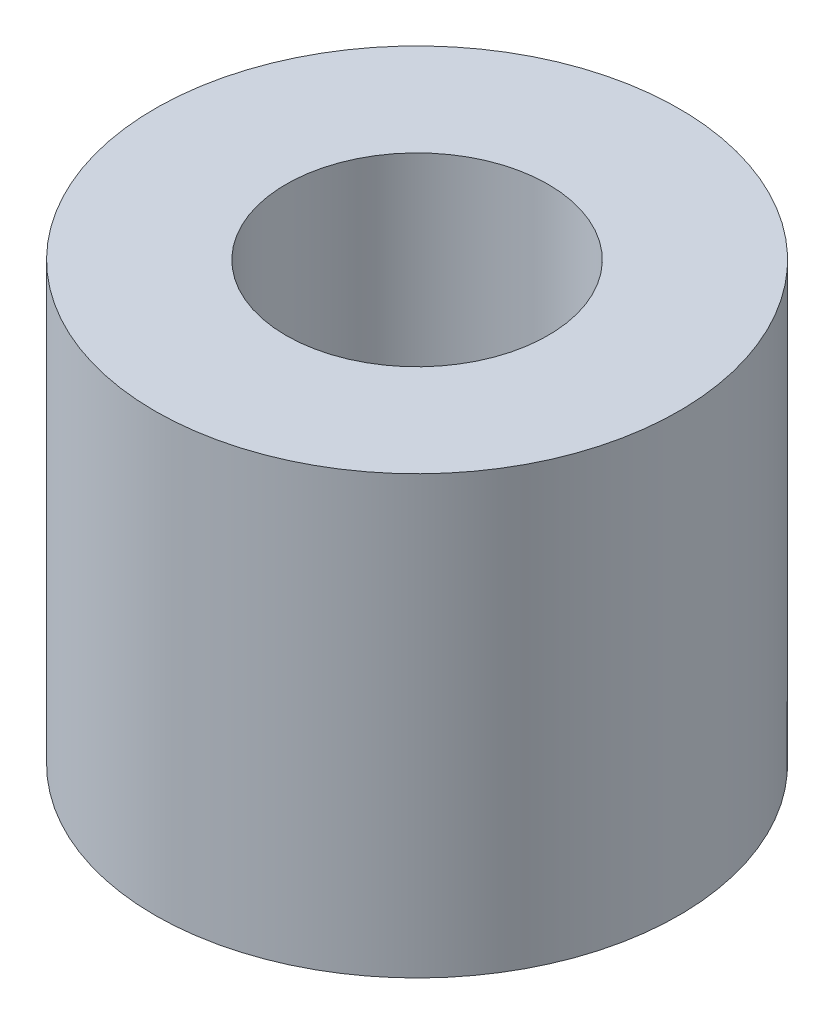
from build123d import *

# Parameters (mm, degrees)
SKETCH1_R           = 3
BOSS_EXTRUDE1_DEPTH = 5
SKETCH2_R           = 1.5
CUT_EXTRUDE1_DEPTH  = 4


with BuildPart() as part:
    # Sketch1 → Boss-Extrude1 (new body)
    with BuildSketch(Plane(origin=(0, 0, 0), x_dir=(1, 0, 0), z_dir=(0, 1, 0))):
        Circle(SKETCH1_R)
    extrude(amount=BOSS_EXTRUDE1_DEPTH)

    # Sketch2 → Cut-Extrude1 (cut)
    with BuildSketch(Plane(origin=(0, 5, 0), x_dir=(1, 0, 0), z_dir=(0, 1, 0))):
        Circle(SKETCH2_R)
    extrude(amount=-CUT_EXTRUDE1_DEPTH, mode=Mode.SUBTRACT)


solid = part.part
